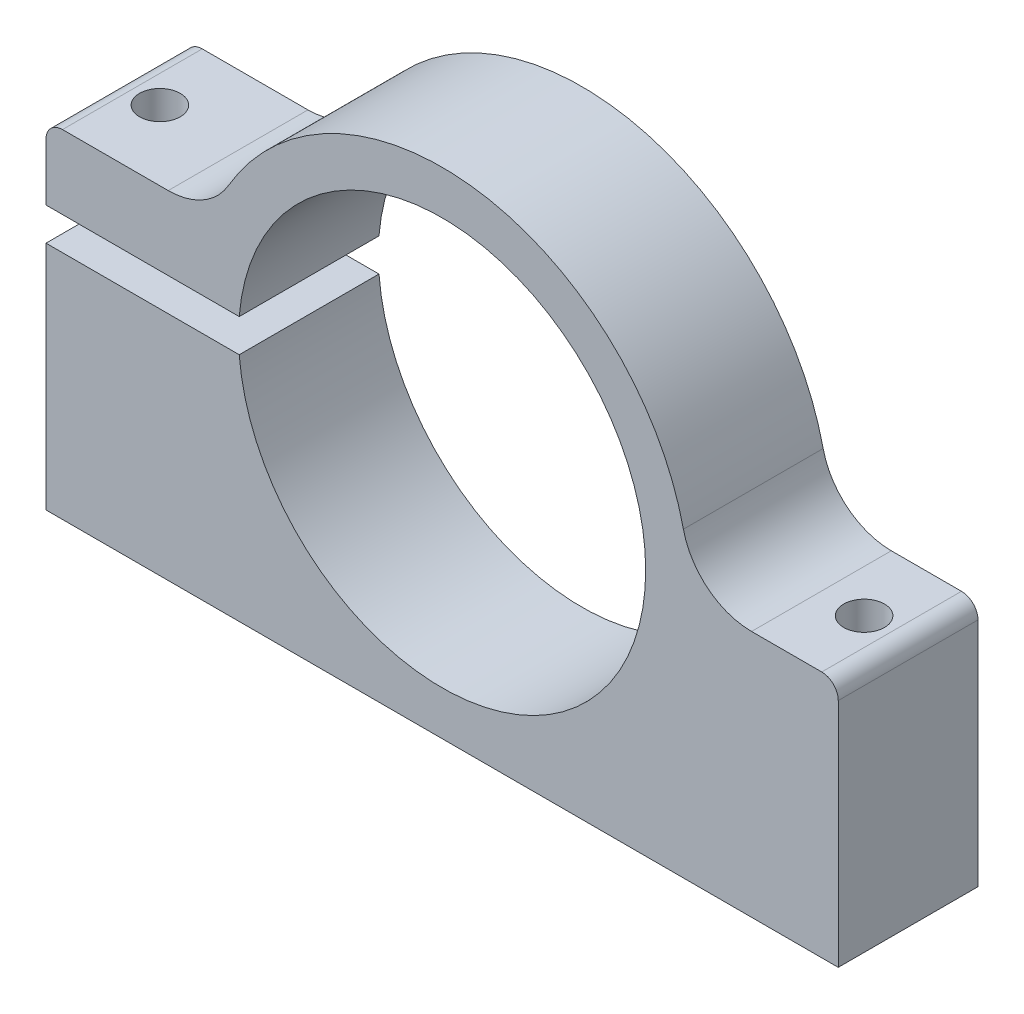
from build123d import *

# Parameters (mm, degrees)
BOSS_EXTRUDE1_DEPTH            = 12.7
CUT_EXTRUDE1_DEPTH             = 13.7
SKETCH3_W                      = 18.5
SKETCH3_H                      = 12.7
F_3_7_3_7_DIAMETER_HOLE1_D     = 3.7
F_3_7_3_7_DIAMETER_HOLE1_DEPTH = 22.5
SKETCH6_W                      = 1.85
SKETCH6_H                      = 20.98
F_3_7_3_7_DIAMETER_HOLE3_D     = 3.7
F_3_7_3_7_DIAMETER_HOLE3_DEPTH = 44.98
FILLET1_R                      = 1.5
FILLET2_R                      = 6.35


with BuildPart() as part:
    # Sketch1 → Boss-Extrude1 (new body)
    with BuildSketch(Plane(origin=(0, 0, -12.299495873), x_dir=(-1, 0, 0), z_dir=(0, 0, -1))):
        with BuildLine():
            Line((24.859325054, -22.385915399), (24.859325054, 8.305102167))
            Line((24.859325054, 8.305102167), (9.793928734, 8.305102167))
            ThreePointArc((9.793928734, 8.305102167), (-15.308438691, 22.204357242), (-33.620674946, 0.114084601))
            Line((-33.620674946, 0.114084601), (-47.140674946, 0.114084601))
            Line((-47.140674946, 0.114084601), (-47.140674946, -22.385915399))
            Line((-47.140674946, -22.385915399), (24.859325054, -22.385915399))
        make_face()
    extrude(amount=-BOSS_EXTRUDE1_DEPTH)

    # Sketch2 → Cut-Extrude1 (cut, through all)
    with BuildSketch(Plane.XY.offset(0.400504127)):
        with BuildLine():
            Line((-24.859325054, 1.614084601), (-24.859325054, -1.385915399))
            Line((-24.859325054, -1.385915399), (-7.298413969, -1.385915399))
            ThreePointArc((-7.298413969, -1.385915399), (-7.359325054, 0.114084601), (-7.298413969, 1.614084601))
            Line((-7.298413969, 1.614084601), (-24.859325054, 1.614084601))
        make_face()
    extrude(amount=-CUT_EXTRUDE1_DEPTH, mode=Mode.SUBTRACT)

    # Sketch3 → Cut-Revolve1 (revolve, cut)
    with BuildSketch(Plane.XZ.offset(-0.114084601)):
        with Locations((20.390674946, -5.949495873)):
            Rectangle(SKETCH3_W, SKETCH3_H)
    revolve(axis=Axis((11.140674946, 0.114084601, 0.400504127), (0, 0, -1)), mode=Mode.SUBTRACT)

    # Ø3.7 (3.7) Diameter Hole1
    with Locations(Plane(origin=(0, 0.114084601, 0), x_dir=(1, 0, 0), z_dir=(0, 1, 0))):
        with Locations((43.140674946, 5.949495873)):
            Hole(F_3_7_3_7_DIAMETER_HOLE1_D / 2, depth=F_3_7_3_7_DIAMETER_HOLE1_DEPTH)

    # Sketch6 → Ø3.7 (3.7) Diameter Hole2 (revolve, cut)
    with BuildSketch(Plane(origin=(-20.859325054, 1.614084601, -5.949495873), x_dir=(0, 0, -1), z_dir=(1, 0, 0))):
        with Locations((0.925, 10.49)):
            Rectangle(SKETCH6_W, SKETCH6_H)
    revolve(axis=Axis((-20.859325054, -4.735915399, -5.949495873), (0, 1, 0)), mode=Mode.SUBTRACT)

    # Ø3.7 (3.7) Diameter Hole3
    with Locations(Plane(origin=(0, -22.385915399, 0), x_dir=(-1, 0, 0), z_dir=(0, -1, 0))):
        with Locations((20.859325054, 5.949495873)):
            Hole(F_3_7_3_7_DIAMETER_HOLE3_D / 2, depth=F_3_7_3_7_DIAMETER_HOLE3_DEPTH)

    # Fillet1
    fillet1_edges = [part.edges().sort_by_distance(p)[0] for p in [
        (47.140674946, 0.114084601, -5.949495873),
        (-24.859325054, 8.305102167, -5.949495873),
    ]]
    fillet(fillet1_edges, radius=FILLET1_R)

    # Fillet2
    fillet2_edges = [part.edges().sort_by_distance(p)[0] for p in [
        (33.620674946, 0.114084601, -5.949495873),
        (-9.793928734, 8.305102167, -5.949495873),
    ]]
    fillet(fillet2_edges, radius=FILLET2_R)


solid = part.part
